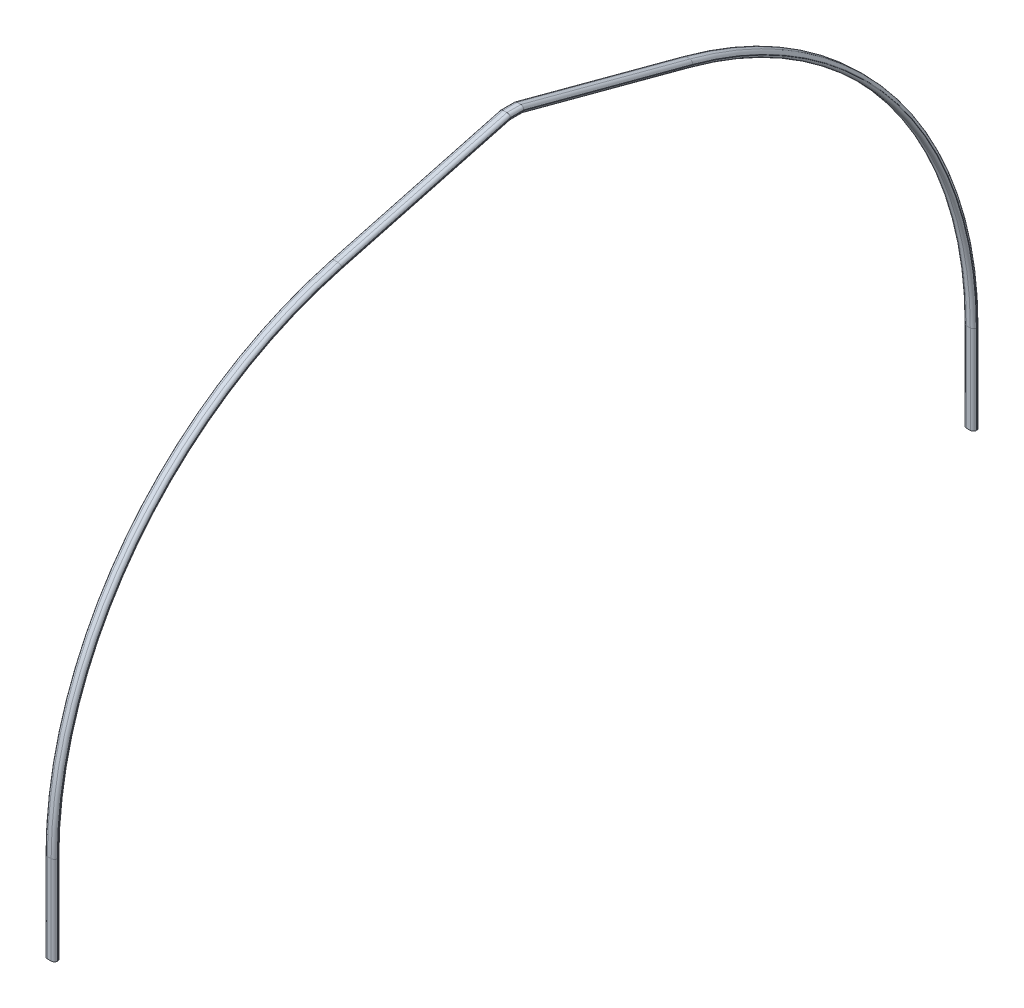
from build123d import *

# Parameters (mm, degrees)
SKETCH5_R          = 6.35
CUT_EXTRUDE1_DEPTH = 12.7
SKETCH6_R          = 6.35
CUT_EXTRUDE2_DEPTH = 12.7


with BuildPart() as part:
    # Sweep1: sweep along a path in Sketch4
    with BuildLine(Plane(origin=(0, 0, 0), x_dir=(0, 0, -1), z_dir=(1, 0, 0))) as sweep1_path:
        Line((0, 0), (0, 882.85962715))
        ThreePointArc((0, 882.85962715), (788.712459745, 3204.049321919), (2828.305301365, 4564.214747031))
        Line((2828.305301365, 4564.214747031), (4506.553686758, 5011.747649802))
        Line((4506.553686758, 5011.747649802), (4637.446313242, 5011.747649802))
        Line((4637.446313242, 5011.747649802), (6315.694698635, 4564.214747031))
        ThreePointArc((6315.694698635, 4564.214747031), (8355.287540255, 3204.049321919), (9144, 882.85962715))
        Line((9144, 882.85962715), (9144, 0))
    # Sketch1 → Sweep1 (sweep)
    with BuildSketch(Plane(origin=(0, 0, 0), x_dir=(1, 0, 0), z_dir=(0, 1, 0))):
        with BuildLine():
            Line((38.1, -31.75), (0, -31.75))
            ThreePointArc((0, -31.75), (-21.533897696, -23.3313898), (-31.648236918, -2.54))
            Line((-31.648236918, -2.54), (-24.13, -2.54))
            Line((-24.13, -2.54), (-24.13, 2.54))
            Line((-24.13, 2.54), (-31.648236918, 2.54))
            ThreePointArc((-31.648236918, 2.54), (-21.533897696, 23.3313898), (0, 31.75))
            Line((0, 31.75), (38.1, 31.75))
            ThreePointArc((38.1, 31.75), (59.633897696, 23.3313898), (69.748236918, 2.54))
            Line((69.748236918, 2.54), (62.23, 2.54))
            Line((62.23, 2.54), (62.23, -2.54))
            Line((62.23, -2.54), (69.748236918, -2.54))
            ThreePointArc((69.748236918, -2.54), (59.633897696, -23.3313898), (38.1, -31.75))
        make_face()
        with BuildLine():
            Line((0, 20.304779167), (38.1, 20.304779167))
            ThreePointArc((38.1, 20.304779167), (58.404779167, 0), (38.1, -20.304779167))
            Line((38.1, -20.304779167), (0, -20.304779167))
            ThreePointArc((0, -20.304779167), (-20.304779167, 0), (0, 20.304779167))
        make_face(mode=Mode.SUBTRACT)
    sweep(path=sweep1_path.line, transition=Transition.RIGHT)

    # Sketch5 → Cut-Extrude1 (cut)
    with BuildSketch(Plane.XZ.offset(-4979.997649802)):
        with Locations((0, -4552.95)):
            Circle(SKETCH5_R)
        with Locations((38.1, -4552.95)):
            Circle(SKETCH5_R)
        with Locations((38.1, -4591.05)):
            Circle(SKETCH5_R)
        with Locations((0, -4591.05)):
            Circle(SKETCH5_R)
    extrude(amount=-CUT_EXTRUDE1_DEPTH, mode=Mode.SUBTRACT)

    # Sketch6 → Cut-Extrude2 (cut)
    with BuildSketch(Plane(origin=(0, 5802.890505398, -1547.437468106), x_dir=(-1, 0, 0), z_dir=(0, -0.96623494, 0.257662651))):
        with Locations((-38.1, 3447.683111644)):
            Circle(SKETCH6_R)
        with Locations((-38.1, 3655.963111644)):
            Circle(SKETCH6_R)
        with Locations((0, 3655.963111644)):
            Circle(SKETCH6_R)
        with Locations((0, 3447.683111644)):
            Circle(SKETCH6_R)
    extrude(amount=-CUT_EXTRUDE2_DEPTH, mode=Mode.SUBTRACT)


solid = part.part
